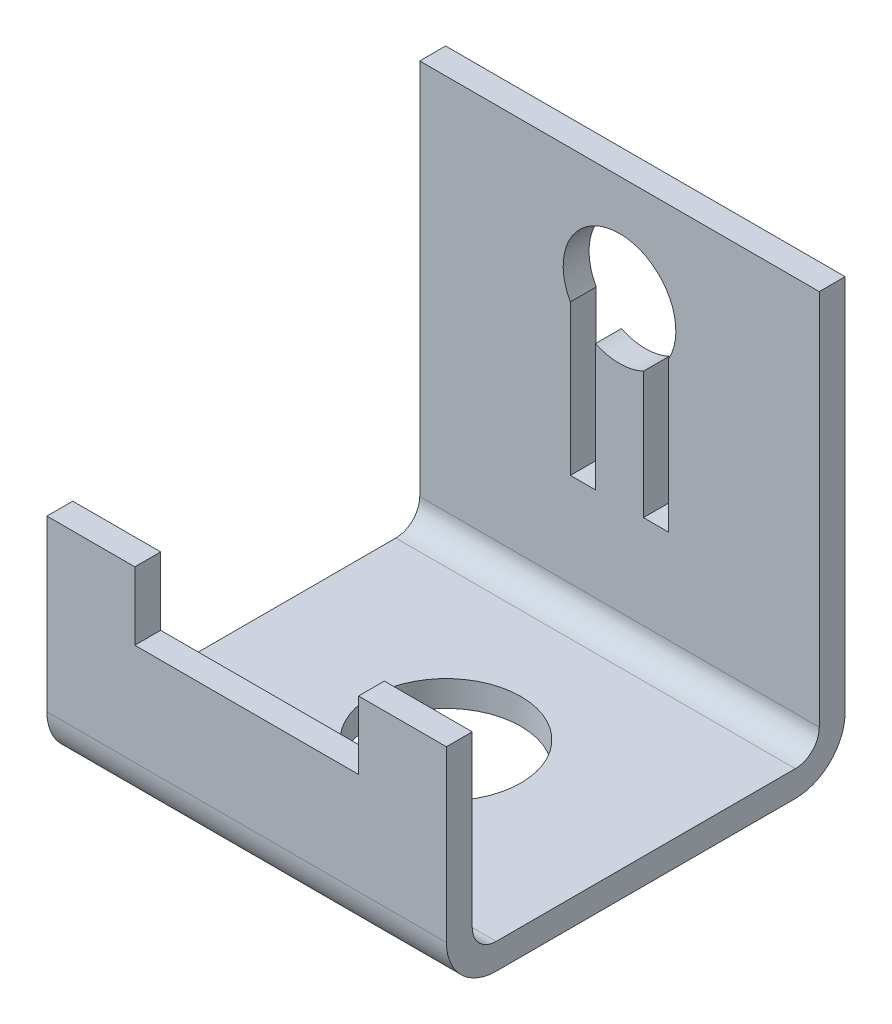
from build123d import *

# Parameters (mm, degrees)
SKETCH1_W           = 25.4
SKETCH1_H           = 25.3492
SKETCH1_R           = 4.7625
BOSS_EXTRUDE1_DEPTH = 1.64338
SKETCH2_W           = 25.4
SKETCH2_H           = 1.64338
BOSS_EXTRUDE2_DEPTH = 7.98322
SKETCH3_W           = 5.588
SKETCH3_H           = 1.64338
BOSS_EXTRUDE3_DEPTH = 4.318
SKETCH4_W           = 25.4
SKETCH4_H           = 1.64338
BOSS_EXTRUDE4_DEPTH = 25.50922
CUT_EXTRUDE1_DEPTH  = 1.64338
FILLET1_R           = 1.524
FILLET2_R           = 3.16738


with BuildPart() as part:
    # Sketch1 → Boss-Extrude1 (new body)
    with BuildSketch(Plane(origin=(0, 0, 0), x_dir=(1, 0, 0), z_dir=(0, 1, 0))):
        Rectangle(SKETCH1_W, SKETCH1_H)
        Circle(SKETCH1_R, mode=Mode.SUBTRACT)
    extrude(amount=BOSS_EXTRUDE1_DEPTH)

    # Sketch2 → Boss-Extrude2 (add)
    with BuildSketch(Plane(origin=(0, 1.64338, 0), x_dir=(1, 0, 0), z_dir=(0, 1, 0))):
        with Locations((0, -11.85291)):
            Rectangle(SKETCH2_W, SKETCH2_H)
    extrude(amount=BOSS_EXTRUDE2_DEPTH)

    # Sketch3 → Boss-Extrude3 (add)
    with BuildSketch(Plane(origin=(0, 9.6266, 0), x_dir=(1, 0, 0), z_dir=(0, 1, 0))):
        with Locations((-9.906, -11.85291)):
            Rectangle(SKETCH3_W, SKETCH3_H)
        with Locations((9.906, -11.85291)):
            Rectangle(SKETCH3_W, SKETCH3_H)
    extrude(amount=BOSS_EXTRUDE3_DEPTH)

    # Sketch4 → Boss-Extrude4 (add)
    with BuildSketch(Plane(origin=(0, 1.64338, 0), x_dir=(1, 0, 0), z_dir=(0, 1, 0))):
        with Locations((0, 11.85291)):
            Rectangle(SKETCH4_W, SKETCH4_H)
    extrude(amount=BOSS_EXTRUDE4_DEPTH)

    # Sketch5 → Cut-Extrude1 (cut)
    with BuildSketch(Plane(origin=(0, 0, -12.6746), x_dir=(-1, 0, 0), z_dir=(0, 0, -1))):
        with BuildLine():
            Line((-3.1242, 9.1186), (-3.1242, 18.670657305))
            ThreePointArc((-3.1242, 18.670657305), (0, 24.003), (3.1242, 18.670657305))
            Line((3.1242, 18.670657305), (3.1242, 9.1186))
            Line((3.1242, 9.1186), (1.524, 9.1186))
            Line((1.524, 9.1186), (1.524, 17.180635644))
            ThreePointArc((1.524, 17.180635644), (0, 16.8402), (-1.524, 17.180635644))
            Line((-1.524, 17.180635644), (-1.524, 9.1186))
            Line((-1.524, 9.1186), (-3.1242, 9.1186))
        make_face()
    extrude(amount=-CUT_EXTRUDE1_DEPTH, mode=Mode.SUBTRACT)

    # Fillet1
    fillet1_edges = [part.edges().sort_by_distance(p)[0] for p in [
        (0, 1.64338, 11.03122),
        (0, 1.64338, -11.03122),
    ]]
    fillet(fillet1_edges, radius=FILLET1_R)

    # Fillet2
    fillet2_edges = [part.edges().sort_by_distance(p)[0] for p in [
        (0, 0, -12.6746),
        (0, 0, 12.6746),
    ]]
    fillet(fillet2_edges, radius=FILLET2_R)


solid = part.part
